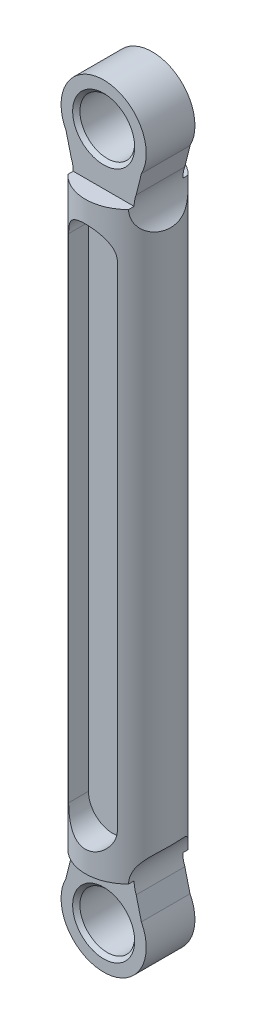
from build123d import *

# Parameters (mm, degrees)
SKETCH1_R           = 3.5
EXTRUDE1_DEPTH      = 48
SKETCH3_W           = 8
SKETCH3_H           = 4
EXTRUDE2_DEPTH      = 9
SKETCH4_R           = 2.25
EXTRUDE3_DEPTH      = 2.5
EXTRUDE3_DEPTH_BACK = 6.5
SKETCH5_W           = 8
SKETCH5_H           = 4
EXTRUDE4_DEPTH      = 10
SKETCH6_R           = 2.25
EXTRUDE9_DEPTH      = 2.5000001
EXTRUDE9_DEPTH_BACK = 6.5000001
EXTRUDE10_DEPTH     = 2.25
EXTRUDE11_DEPTH     = 2.25
CHAMFER1_SIZE       = 0.3


with BuildPart() as part:
    # Sketch1 → Extrude1 (new body)
    with BuildSketch(Plane(origin=(0, 0, 0), x_dir=(1, 0, 0), z_dir=(0, 1, 0))):
        with Locations(Location((0, 0, 0), (0, 0, 270))):  # turned: the seam where the file's is
            Circle(SKETCH1_R)
    extrude(amount=EXTRUDE1_DEPTH)

    # Sketch3 → Extrude2 (add)
    with BuildSketch(Plane(origin=(0, 48, 0), x_dir=(1, 0, 0), z_dir=(0, 1, 0))):
        Rectangle(SKETCH3_W, SKETCH3_H)
    extrude(amount=EXTRUDE2_DEPTH)

    # Sketch4 → Extrude3 (cut, two sides)
    with BuildSketch(Plane.XY.offset(2)) as extrude3_sk:
        with Locations((0, 52.25)):
            Circle(SKETCH4_R)
        with BuildLine():
            Line((-7.499970708, 47.987897931), (-8.595568017, 58.173135503))
            Line((-8.595568017, 58.173135503), (8.858273183, 57.495072607))
            Line((8.858273183, 57.495072607), (7.499969018, 47.987553821))
            ThreePointArc((7.499969018, 47.987553821), (4.534958441, 45.531181463), (2.672956888, 48.901345124))
            Line((2.672956888, 48.901345124), (3.097561986, 50.620549251))
            ThreePointArc((3.097561986, 50.620549251), (0, 55.75), (-3.097561986, 50.620549251))
            Line((-3.097561986, 50.620549251), (-2.672956888, 48.901345124))
            ThreePointArc((-2.672956888, 48.901345124), (-4.53465869, 45.531582657), (-7.499970708, 47.987897931))
        make_face()
    extrude(amount=EXTRUDE3_DEPTH, mode=Mode.SUBTRACT)
    extrude(extrude3_sk.sketch, amount=-EXTRUDE3_DEPTH_BACK, mode=Mode.SUBTRACT)

    # Sketch5 → Extrude4 (add)
    with BuildSketch(Plane.XZ):
        Rectangle(SKETCH5_W, SKETCH5_H)
    extrude(amount=EXTRUDE4_DEPTH)

    # Sketch6 → Extrude9 (cut, two sides)
    with BuildSketch(Plane(origin=(0, 0, -2), x_dir=(-1, 0, 0), z_dir=(0, 0, -1))) as extrude9_sk:
        with Locations((0, -4.25)):
            Circle(SKETCH6_R)
        with BuildLine():
            Line((-3.097561986, -2.620549251), (-2.672956888, -0.901345124))
            ThreePointArc((-2.672956888, -0.901345124), (-4.53465869, 2.468417343), (-7.499970708, 0.012102069))
            Line((-7.499970708, 0.012102069), (-8.700661362, -11.644211871))
            Line((-8.700661362, -11.644211871), (9.512578745, -12.130566681))
            Line((9.512578745, -12.130566681), (7.499969018, 0.012446179))
            ThreePointArc((7.499969018, 0.012446179), (4.534958441, 2.468818537), (2.672956888, -0.901345124))
            Line((2.672956888, -0.901345124), (3.097561986, -2.620549251))
            ThreePointArc((3.097561986, -2.620549251), (0, -7.75), (-3.097561986, -2.620549251))
        make_face()
    extrude(amount=EXTRUDE9_DEPTH, mode=Mode.SUBTRACT)
    extrude(extrude9_sk.sketch, amount=-EXTRUDE9_DEPTH_BACK, mode=Mode.SUBTRACT)

    # Sketch7 → Extrude10 (cut)
    with BuildSketch(Plane.XY.offset(3.5)):
        with BuildLine():
            ThreePointArc((0, 46.25), (-1.414213562, 45.664213562), (-2, 44.25))
            Line((-2, 44.25), (-2, 3.75))
            ThreePointArc((-2, 3.75), (-1.414213562, 2.335786438), (0, 1.75))
            ThreePointArc((0, 1.75), (1.414213562, 2.335786438), (2, 3.75))
            Line((2, 3.75), (2, 44.25))
            ThreePointArc((2, 44.25), (1.414213562, 45.664213562), (0, 46.25))
        make_face()
    extrude(amount=-EXTRUDE10_DEPTH, mode=Mode.SUBTRACT)

    # Sketch8 → Extrude11 (cut)
    with BuildSketch(Plane(origin=(0, 0, -3.5), x_dir=(-1, 0, 0), z_dir=(0, 0, -1))):
        with BuildLine():
            Line((-2, 44.25), (-2, 3.75))
            ThreePointArc((-2, 3.75), (0, 1.75), (2, 3.75))
            Line((2, 3.75), (2, 44.25))
            ThreePointArc((2, 44.25), (0, 46.25), (-2, 44.25))
        make_face()
    extrude(amount=-EXTRUDE11_DEPTH, mode=Mode.SUBTRACT)

    # Chamfer1
    chamfer1_edges = [part.edges().sort_by_distance(p)[0] for p in [
        (-2.25, 52.25, -2),
        (-2.25, 52.25, 2),
        (2.25, -4.25, -2),
        (2.25, -4.25, 2),
    ]]
    chamfer(chamfer1_edges, length=CHAMFER1_SIZE)


solid = part.part
